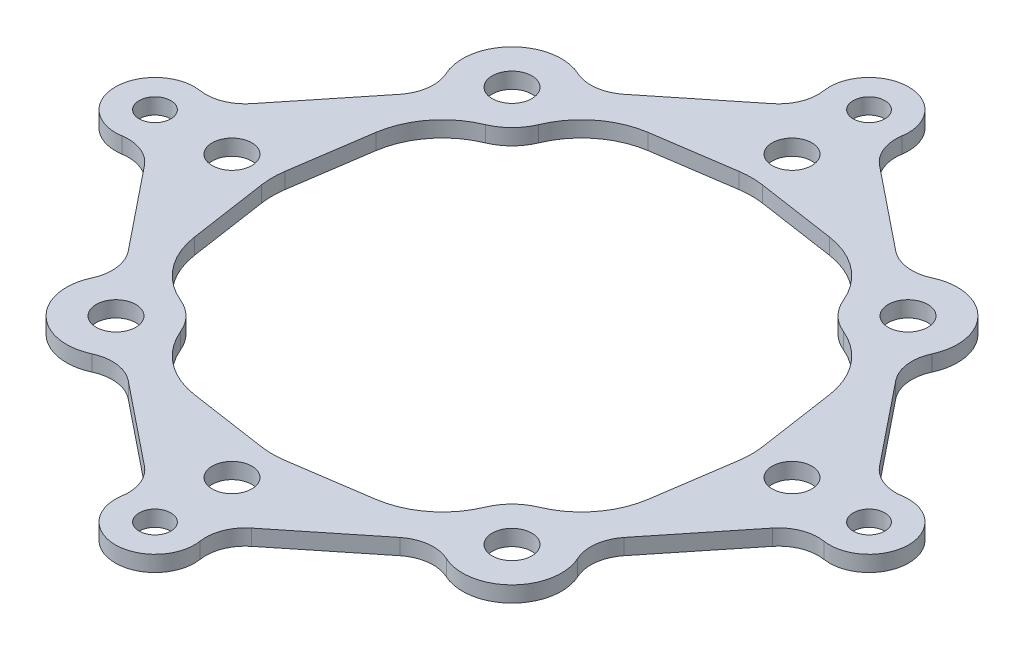
from build123d import *

# Parameters (mm, degrees)
EXTRUDE_1_DEPTH = 0.8
FILLET_1_R      = 4
FILLET_2_R      = 2


with BuildPart() as part:
    # 草图1 → 凸台-拉伸1 (new body)
    with BuildSketch(Plane(origin=(0, 0, 0), x_dir=(1, 0, 0), z_dir=(0, 1, 0))):
        with BuildLine():
            ThreePointArc((1.559359784, 16.778866316), (1.803429124, 18.895886668), (0, 20.03122292))
            Line((0, 20.03122292), (0, 18.83122292))
            ThreePointArc((0, 18.83122292), (0.8, 18.03122292), (0, 17.23122292))
            Line((0, 17.23122292), (0, 15.142135624))
            ThreePointArc((0, 15.142135624), (1, 14.142135624), (0, 13.142135624))
            Line((0, 13.142135624), (0, 12.142135624))
            Line((0, 12.142135624), (7.708712153, 11))
            ThreePointArc((7.708712153, 11), (7.543556444, 9.535365676), (8.232233047, 8.232233047))
            Line((8.232233047, 8.232233047), (9.292893219, 9.292893219))
            ThreePointArc((9.292893219, 9.292893219), (9.292893219, 10.707106781), (10.707106781, 10.707106781))
            Line((10.707106781, 10.707106781), (11.767766953, 11.767766953))
            ThreePointArc((11.767766953, 11.767766953), (9.864121635, 12.496304683), (8.05080027, 11.565445755))
            Line((8.05080027, 11.565445755), (1.559359784, 16.778866316))
        make_face()
    extrude_1 = extrude(amount=EXTRUDE_1_DEPTH)

    # 镜向1: 凸台-拉伸1 across plane
    add(extrude_1.mirror(Plane(origin=(0, 0.8, 0), x_dir=(-0.707106781, 0, 0.707106781), z_dir=(-0.707106781, 0, -0.707106781))))

    # 镜向2: part across plane


with BuildPart() as part_1:
    add(part.part)
    add(part.part.mirror(Plane(origin=(0, 0.8, 0), x_dir=(0, 0, 1), z_dir=(1, 0, 0))))

    # 镜向3: part across plane


with BuildPart() as part_2:
    add(part_1.part)
    add(part_1.part.mirror(Plane(origin=(0, 0.8, 0), x_dir=(1, 0, 0), z_dir=(0, 0, 1))))

    # 圆角1
    fillet_1_edges = [part_2.edges().sort_by_distance(p)[0] for p in [
        (7.708712153, 0.4, 11),
        (11, 0.4, 7.708712153),
        (12.142135624, 0.4, 0),
        (0, 0.4, 12.142135624),
        (-7.708712153, 0.4, 11),
        (-11, 0.4, 7.708712153),
        (-12.142135624, 0.4, 0),
        (7.708712153, 0.4, -11),
        (11, 0.4, -7.708712153),
        (0, 0.4, -12.142135624),
        (-7.708712153, 0.4, -11),
        (-11, 0.4, -7.708712153),
    ]]
    fillet(fillet_1_edges, radius=FILLET_1_R)

    # 圆角2
    fillet_2_edges = [part_2.edges().sort_by_distance(p)[0] for p in [
        (8.05080027, 0.4, 11.565445755),
        (1.559359784, 0.4, 16.778866316),
        (-1.559359784, 0.4, 16.778866316),
        (16.778866316, 0.4, 1.559359784),
        (11.565445755, 0.4, 8.05080027),
        (-11.565445755, 0.4, 8.05080027),
        (-8.05080027, 0.4, 11.565445755),
        (-16.778866316, 0.4, 1.559359784),
        (1.559359784, 0.4, -16.778866316),
        (8.05080027, 0.4, -11.565445755),
        (16.778866316, 0.4, -1.559359784),
        (11.565445755, 0.4, -8.05080027),
        (-8.05080027, 0.4, -11.565445755),
        (-1.559359784, 0.4, -16.778866316),
        (-16.778866316, 0.4, -1.559359784),
        (-11.565445755, 0.4, -8.05080027),
    ]]
    fillet(fillet_2_edges, radius=FILLET_2_R)


solid = part_2.part
